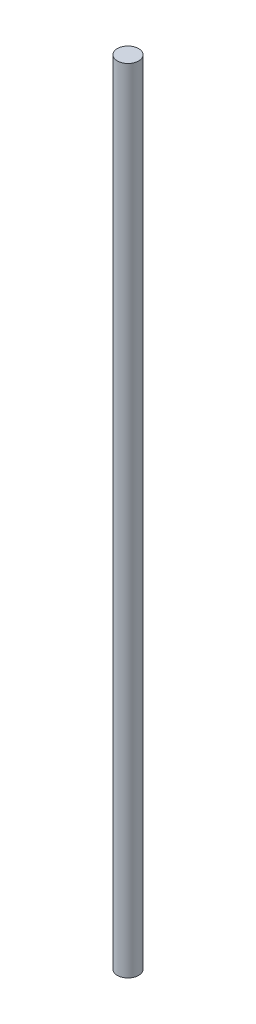
from build123d import *

# Parameters (mm, degrees)
ESQUISSE1_R        = 1.5
BOSS_EXTRU_1_DEPTH = 111


with BuildPart() as part:
    # Esquisse1 → Boss.-Extru.1 (new body)
    with BuildSketch(Plane(origin=(0, 0, 0), x_dir=(1, 0, 0), z_dir=(0, 1, 0))):
        Circle(ESQUISSE1_R)
    extrude(amount=BOSS_EXTRU_1_DEPTH)


solid = part.part
